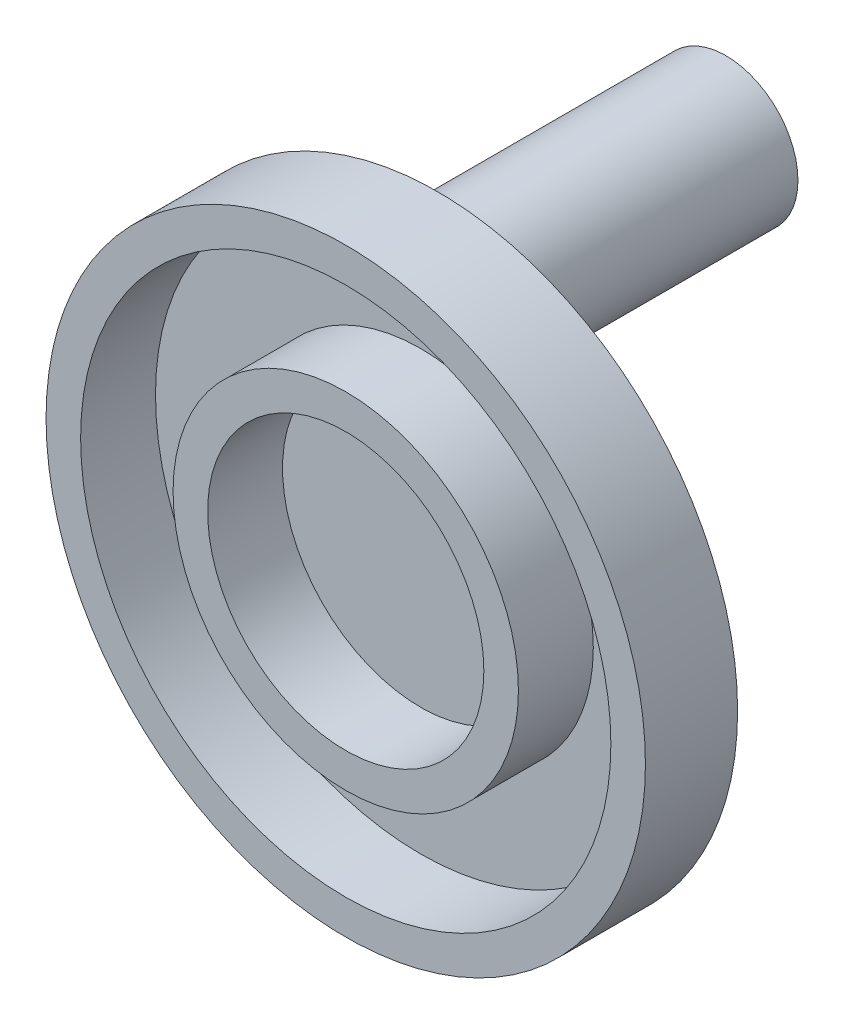
from build123d import *

# Parameters (mm, degrees)
SKETCH1_R           = 12.5
BOSS_EXTRUDE1_DEPTH = 50
SKETCH2_R           = 52.025
SKETCH2_R_2         = 46.025
SKETCH2_R_3         = 29.975
SKETCH2_R_4         = 23.975
BOSS_EXTRUDE2_DEPTH = 16
SKETCH4_R           = 52.025
BOSS_EXTRUDE3_DEPTH = 3


with BuildPart() as part:
    # Sketch1 → Boss-Extrude1 (new body)
    with BuildSketch(Plane.XY):
        Circle(SKETCH1_R)
    extrude(amount=-BOSS_EXTRUDE1_DEPTH)

    # Sketch2 → Boss-Extrude2 (add)
    with BuildSketch(Plane.XY):
        with Locations((0, -35)):
            Circle(SKETCH2_R)
        with Locations((0, -35)):
            Circle(SKETCH2_R_2, mode=Mode.SUBTRACT)
        with Locations((0, -35)):
            Circle(SKETCH2_R_3)
        with Locations((0, -35)):
            Circle(SKETCH2_R_4, mode=Mode.SUBTRACT)
    extrude(amount=BOSS_EXTRUDE2_DEPTH)

    # Sketch4 → Boss-Extrude3 (add)
    with BuildSketch(Plane.XY):
        with Locations((0, -35)):
            Circle(SKETCH4_R)
    extrude(amount=BOSS_EXTRUDE3_DEPTH)


solid = part.part
